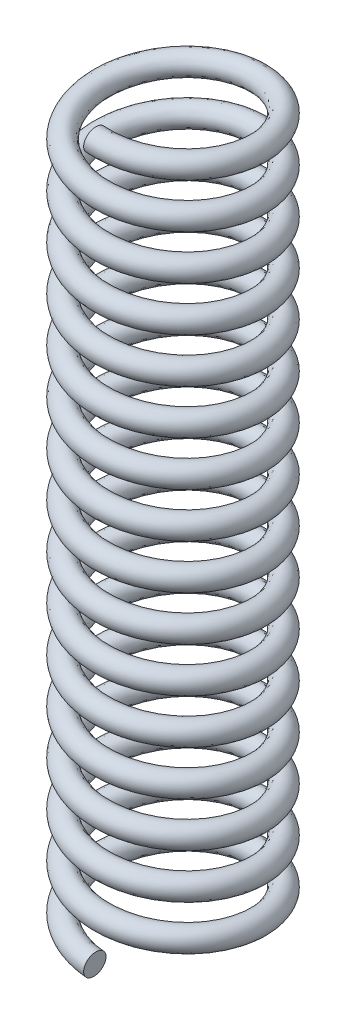
from build123d import *

# Parameters (mm, degrees)
SWEEP1_PITCH  = 2
SWEEP1_HEIGHT = 32
SWEEP1_RADIUS = 3.5
SKETCH2_R     = 0.5


with BuildPart() as part:
    # Sweep1: sweep along a helix
    with BuildLine() as sweep1_path:
        Helix(SWEEP1_PITCH, SWEEP1_HEIGHT, SWEEP1_RADIUS, center=(0, 0, 0), direction=(0, 1, 0), lefthand=True)
    # Sketch2 → Sweep1 (sweep)
    with BuildSketch(Plane(origin=(0, 0, 3.5), x_dir=(0, 0, 1), z_dir=(-0.99588992, 0.090571888, 0))):
        Circle(SKETCH2_R)
    sweep(path=sweep1_path.line, is_frenet=True)


solid = part.part
